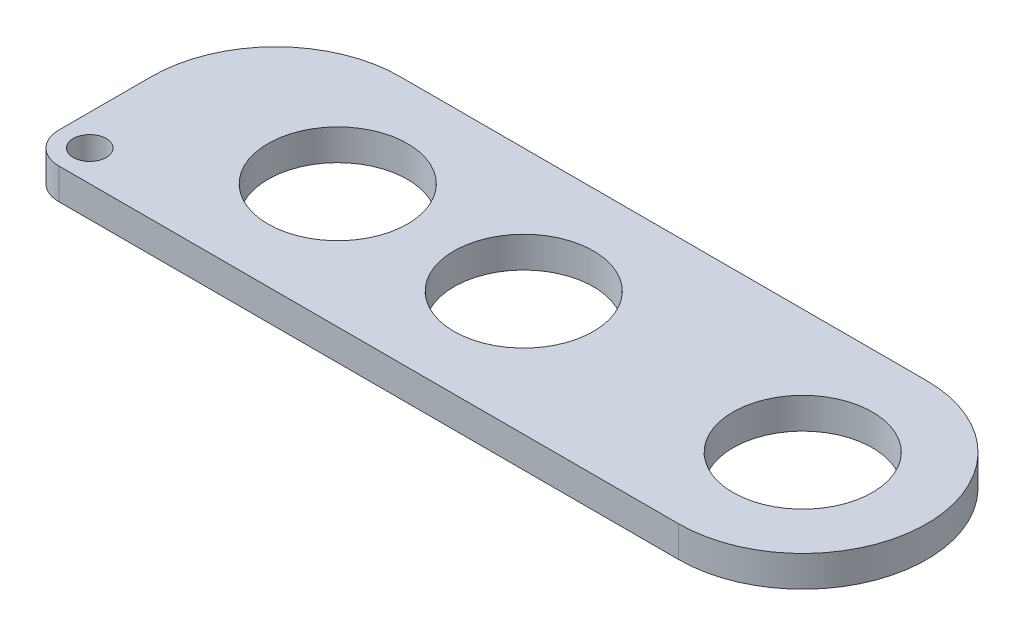
from build123d import *

# Parameters (mm, degrees)
BOSS_EXTRUDE1_DEPTH     = 6.35
SKETCH2_R               = 14.2875
CUT_EXTRUDE1_DEPTH      = 7.35
F_1_4_CLEARANCE_HOLE1_D = 6.7564
FILLET1_R               = 6.35
FILLET2_R               = 25.4


with BuildPart() as part:
    # Sketch1 → Boss-Extrude1 (new body)
    with BuildSketch(Plane(origin=(0, 0, 0), x_dir=(1, 0, 0), z_dir=(0, 1, 0))):
        with BuildLine():
            Line((-38.1, 25.4), (95.25, 25.4))
            ThreePointArc((95.25, 25.4), (120.65, 0), (95.25, -25.4))
            Line((95.25, -25.4), (-38.1, -25.4))
            Line((-38.1, -25.4), (-38.1, 25.4))
        make_face()
    extrude(amount=BOSS_EXTRUDE1_DEPTH)

    # Sketch2 → Cut-Extrude1 (cut, through all)
    with BuildSketch(Plane(origin=(0, 6.35, 0), x_dir=(1, 0, 0), z_dir=(0, 1, 0))):
        with Locations((38.1, 0)):
            Circle(SKETCH2_R)
        with Locations((95.25, 0)):
            Circle(SKETCH2_R)
        Circle(SKETCH2_R)
    extrude(amount=-CUT_EXTRUDE1_DEPTH, mode=Mode.SUBTRACT)

    # 1/4 Clearance Hole1 (through all)
    with Locations(Plane(origin=(0, 6.35, 0), x_dir=(1, 0, 0), z_dir=(0, 1, 0))):
        with Locations((-31.75, -19.05)):
            Hole(F_1_4_CLEARANCE_HOLE1_D / 2)

    # Fillet1
    fillet1_edges = [part.edges().sort_by_distance(p)[0] for p in [
        (-38.1, 3.175, 25.4),
    ]]
    fillet(fillet1_edges, radius=FILLET1_R)

    # Fillet2
    fillet2_edges = [part.edges().sort_by_distance(p)[0] for p in [
        (-38.1, 3.175, -25.4),
    ]]
    fillet(fillet2_edges, radius=FILLET2_R)


solid = part.part
